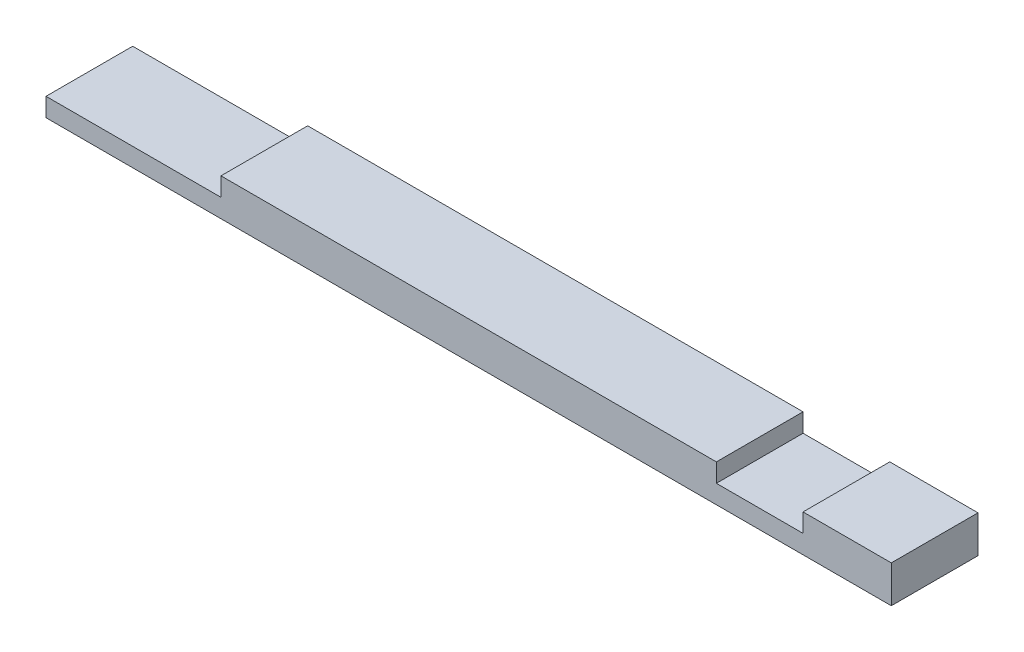
from build123d import *

# Parameters (mm, degrees)
SKETCH1_W           = 866.775
SKETCH1_H           = 88.9
BOSS_EXTRUDE1_DEPTH = 38.1
SKETCH2_W           = 88.9
SKETCH2_H           = 88.9
SKETCH2_W_2         = 179.4002
CUT_EXTRUDE1_DEPTH  = 19.05


with BuildPart() as part:
    # Sketch1 → Boss-Extrude1 (new body)
    with BuildSketch(Plane(origin=(0, 0, 0), x_dir=(1, 0, 0), z_dir=(0, 1, 0))):
        with Locations((433.3875, 44.45)):
            Rectangle(SKETCH1_W, SKETCH1_H)
    extrude(amount=BOSS_EXTRUDE1_DEPTH)

    # Sketch2 → Cut-Extrude1 (cut)
    with BuildSketch(Plane(origin=(0, 38.1, 0), x_dir=(1, 0, 0), z_dir=(0, 1, 0))):
        with Locations((731.8375, 44.45)):
            Rectangle(SKETCH2_W, SKETCH2_H)
        with Locations((89.7001, 44.45)):
            Rectangle(SKETCH2_W_2, SKETCH2_H)
    extrude(amount=-CUT_EXTRUDE1_DEPTH, mode=Mode.SUBTRACT)


solid = part.part
